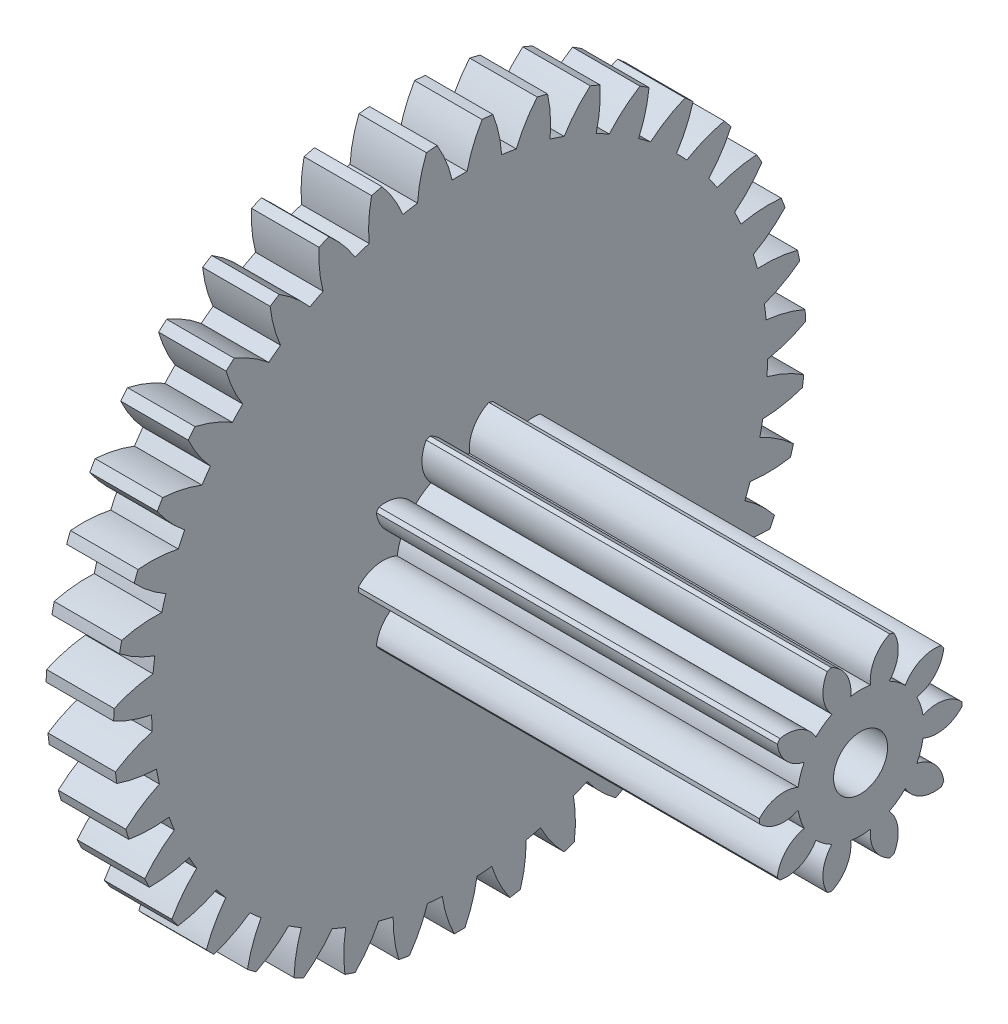
from build123d import *

# Parameters (mm, degrees)
ESQUISSE1_W                         = 1
ESQUISSE1_H                         = 5.125
ENL_V_MAT_EXTRU_1_DEPTH             = 2
ENL_V_MAT_EXTRU_2_DEPTH             = 2
ENL_V_MAT_EXTRU_3_DEPTH             = 2
ENL_V_MAT_EXTRU_4_DEPTH             = 2
ENL_V_MAT_EXTRU_5_DEPTH             = 2
ENL_V_MAT_EXTRU_6_DEPTH             = 2
ENL_V_MAT_EXTRU_7_DEPTH             = 2
ENL_V_MAT_EXTRU_8_DEPTH             = 2
ENL_V_MAT_EXTRU_9_DEPTH             = 2
ENL_V_MAT_EXTRU_10_DEPTH            = 2
ENL_V_MAT_EXTRU_11_DEPTH            = 2
ENL_V_MAT_EXTRU_12_DEPTH            = 2
ENL_V_MAT_EXTRU_13_DEPTH            = 2
ENL_V_MAT_EXTRU_14_DEPTH            = 2
ENL_V_MAT_EXTRU_15_DEPTH            = 2
ENL_V_MAT_EXTRU_16_DEPTH            = 2
ENL_V_MAT_EXTRU_17_DEPTH            = 2
ENL_V_MAT_EXTRU_18_DEPTH            = 2
ENL_V_MAT_EXTRU_19_DEPTH            = 2
ENL_V_MAT_EXTRU_20_DEPTH            = 2
ENL_V_MAT_EXTRU_21_DEPTH            = 2
ENL_V_MAT_EXTRU_22_DEPTH            = 2
ENL_V_MAT_EXTRU_23_DEPTH            = 2
ENL_V_MAT_EXTRU_24_DEPTH            = 2
ENL_V_MAT_EXTRU_25_DEPTH            = 2
ENL_V_MAT_EXTRU_26_DEPTH            = 2
ENL_V_MAT_EXTRU_27_DEPTH            = 2
ENL_V_MAT_EXTRU_28_DEPTH            = 2
ENL_V_MAT_EXTRU_29_DEPTH            = 2
ENL_V_MAT_EXTRU_30_DEPTH            = 2
ENL_V_MAT_EXTRU_31_DEPTH            = 2
ENL_V_MAT_EXTRU_32_DEPTH            = 2
ENL_V_MAT_EXTRU_33_DEPTH            = 2
ENL_V_MAT_EXTRU_34_DEPTH            = 2
ENL_V_MAT_EXTRU_35_DEPTH            = 2
ENL_V_MAT_EXTRU_36_DEPTH            = 2
ENL_V_MAT_EXTRU_37_DEPTH            = 2
ENL_V_MAT_EXTRU_38_DEPTH            = 2
ENL_V_MAT_EXTRU_39_DEPTH            = 2
BOSS_EXTRU_1_DEPTH                  = 5.938524524
DIAM_TRE_DU_PER_AGE_0_8_0_8_1_D     = 0.8
DIAM_TRE_DU_PER_AGE_0_8_0_8_1_DEPTH = 6.938524524


with BuildPart() as part:
    # Esquisse1 → Révolution1 (revolve)
    with BuildSketch(Plane(origin=(0, 0, 0), x_dir=(-1, 0, 0), z_dir=(0, 0, -1))):
        with Locations((-0.5, 2.5625)):
            Rectangle(ESQUISSE1_W, ESQUISSE1_H)
    revolve(axis=Axis((1, 0, 0), (-1, 0, 0)))

    # Esquisse2 → Enlèv. mat.-Extru.1 (cut, through all)
    with BuildSketch(Plane.ZY):
        with BuildLine():
            ThreePointArc((-0.491599352, 5.101367961), (-0.822107814, 5.058632596), (-1.149140058, 4.994507196))
            ThreePointArc((-1.149140058, 4.994507196), (-0.974871828, 4.75090918), (-0.839964848, 4.483496549))
            ThreePointArc((-0.839964848, 4.483496549), (-0.731716058, 4.502429773), (-0.623042589, 4.518749847))
            ThreePointArc((-0.623042589, 4.518749847), (-0.579759423, 4.815121196), (-0.491599352, 5.101367961))
        make_face()
    extrude(amount=-ENL_V_MAT_EXTRU_1_DEPTH, mode=Mode.SUBTRACT)

    # Esquisse3 → Enlèv. mat.-Extru.2 (cut, through all)
    with BuildSketch(Plane.ZY):
        with BuildLine():
            ThreePointArc((0.3330837, 5.114164668), (0, 5.125), (-0.3330837, 5.114164668))
            ThreePointArc((-0.3330837, 5.114164668), (-0.200148067, 4.845766593), (-0.1098841, 4.560176283))
            ThreePointArc((-0.1098841, 4.560176283), (0, 4.5615), (0.1098841, 4.560176283))
            ThreePointArc((0.1098841, 4.560176283), (0.200148067, 4.845766593), (0.3330837, 5.114164668))
        make_face()
    extrude(amount=-ENL_V_MAT_EXTRU_2_DEPTH, mode=Mode.SUBTRACT)

    # Esquisse4 → Enlèv. mat.-Extru.3 (cut, through all)
    with BuildSketch(Plane.ZY):
        with BuildLine():
            ThreePointArc((1.149140058, 4.994507196), (0.822107814, 5.058632596), (0.491599352, 5.101367961))
            ThreePointArc((0.491599352, 5.101367961), (0.579759423, 4.815121196), (0.623042589, 4.518749847))
            ThreePointArc((0.623042589, 4.518749847), (0.731716058, 4.502429773), (0.839964848, 4.483496549))
            ThreePointArc((0.839964848, 4.483496549), (0.974871828, 4.75090918), (1.149140058, 4.994507196))
        make_face()
    extrude(amount=-ENL_V_MAT_EXTRU_3_DEPTH, mode=Mode.SUBTRACT)

    # Esquisse5 → Enlèv. mat.-Extru.4 (cut, through all)
    with BuildSketch(Plane.ZY):
        with BuildLine():
            ThreePointArc((1.935434293, 4.745494611), (1.622923468, 4.861249265), (1.303550238, 4.956448504))
            ThreePointArc((1.303550238, 4.956448504), (1.34465145, 4.65976669), (1.339832802, 4.360290164))
            ThreePointArc((1.339832802, 4.360290164), (1.444481054, 4.32674898), (1.548290948, 4.290696609))
            ThreePointArc((1.548290948, 4.290696609), (1.724346921, 4.533005716), (1.935434293, 4.745494611))
        make_face()
    extrude(amount=-ENL_V_MAT_EXTRU_4_DEPTH, mode=Mode.SUBTRACT)

    # Esquisse6 → Enlèv. mat.-Extru.5 (cut, through all)
    with BuildSketch(Plane.ZY):
        with BuildLine():
            ThreePointArc((2.671601796, 4.373576208), (2.381706257, 4.537962131), (2.081739858, 4.683159635))
            ThreePointArc((2.081739858, 4.683159635), (2.07471771, 4.383726673), (2.021922049, 4.088901256))
            ThreePointArc((2.021922049, 4.088901256), (2.119834749, 4.039007661), (2.216517126, 3.986769881))
            ThreePointArc((2.216517126, 3.986769881), (2.429162334, 4.197699784), (2.671601796, 4.373576208))
        make_face()
    extrude(amount=-ENL_V_MAT_EXTRU_5_DEPTH, mode=Mode.SUBTRACT)

    # Esquisse7 → Enlèv. mat.-Extru.6 (cut, through all)
    with BuildSketch(Plane.ZY):
        with BuildLine():
            ThreePointArc((3.338576216, 3.888384478), (3.078804104, 4.097144162), (2.806013509, 4.28857939))
            ThreePointArc((2.806013509, 4.28857939), (2.751049871, 3.994150439), (2.651644577, 3.711611952))
            ThreePointArc((2.651644577, 3.711611952), (2.740285838, 3.646658165), (2.827336674, 3.579587907))
            ThreePointArc((2.827336674, 3.579587907), (3.071063719, 3.753675633), (3.338576216, 3.888384478))
        make_face()
    extrude(amount=-ENL_V_MAT_EXTRU_6_DEPTH, mode=Mode.SUBTRACT)

    # Esquisse8 → Enlèv. mat.-Extru.7 (cut, through all)
    with BuildSketch(Plane.ZY):
        with BuildLine():
            ThreePointArc((3.919083265, 3.302485634), (3.696162543, 3.550212312), (3.457612884, 3.782927193))
            ThreePointArc((3.457612884, 3.782927193), (3.356131286, 3.501127806), (3.212690904, 3.23819385))
            ThreePointArc((3.212690904, 3.23819385), (3.289764964, 3.159862139), (3.364929688, 3.079696486))
            ThreePointArc((3.364929688, 3.079696486), (3.633426167, 3.212433254), (3.919083265, 3.302485634))
        make_face()
    extrude(amount=-ENL_V_MAT_EXTRU_7_DEPTH, mode=Mode.SUBTRACT)

    # Esquisse9 → Enlèv. mat.-Extru.8 (cut, through all)
    with BuildSketch(Plane.ZY):
        with BuildLine():
            ThreePointArc((4.398088117, 2.631054146), (4.217792313, 2.911331827), (4.019661902, 3.179299168))
            ThreePointArc((4.019661902, 3.179299168), (3.874290663, 2.917427803), (3.690530223, 2.680908227))
            ThreePointArc((3.690530223, 2.680908227), (3.754040904, 2.591227342), (3.81537279, 2.500042544))
            ThreePointArc((3.81537279, 2.500042544), (4.101684785, 2.587990542), (4.398088117, 2.631054146))
        make_face()
    extrude(amount=-ENL_V_MAT_EXTRU_8_DEPTH, mode=Mode.SUBTRACT)

    # Esquisse10 → Enlèv. mat.-Extru.9 (cut, through all)
    with BuildSketch(Plane.ZY):
        with BuildLine():
            ThreePointArc((4.763184796, 1.891479738), (4.630183477, 2.197049377), (4.477603787, 2.493328964))
            ThreePointArc((4.477603787, 2.493328964), (4.292107947, 2.258167951), (4.072786749, 2.054188489))
            ThreePointArc((4.072786749, 2.054188489), (4.121089157, 1.955481119), (4.166999741, 1.855638814))
            ThreePointArc((4.166999741, 1.855638814), (4.463711922, 1.896520234), (4.763184796, 1.891479738))
        make_face()
    extrude(amount=-ENL_V_MAT_EXTRU_9_DEPTH, mode=Mode.SUBTRACT)

    # Esquisse11 → Enlèv. mat.-Extru.10 (cut, through all)
    with BuildSketch(Plane.ZY):
        with BuildLine():
            ThreePointArc((5.004917491, 1.102916998), (4.922655322, 1.425864503), (4.819578087, 1.74278285))
            ThreePointArc((4.819578087, 1.74278285), (4.59876189, 1.540422736), (4.349560237, 1.374266349))
            ThreePointArc((4.349560237, 1.374266349), (4.381403366, 1.269088962), (4.410703588, 1.163175012))
            ThreePointArc((4.410703588, 1.163175012), (4.710131265, 1.155931048), (5.004917491, 1.102916998))
        make_face()
    extrude(amount=-ENL_V_MAT_EXTRU_10_DEPTH, mode=Mode.SUBTRACT)

    # Esquisse12 → Enlèv. mat.-Extru.11 (cut, through all)
    with BuildSketch(Plane.ZY):
        with BuildLine():
            ThreePointArc((5.117025453, 0.285789287), (5.08763298, 0.617750486), (5.036727846, 0.947099576))
            ThreePointArc((5.036727846, 0.947099576), (4.786310315, 0.782781381), (4.513682399, 0.658751432))
            ThreePointArc((4.513682399, 0.658751432), (4.528241529, 0.549828067), (4.540172528, 0.440585589))
            ThreePointArc((4.540172528, 0.440585589), (4.834560682, 0.385403856), (5.117025453, 0.285789287))
        make_face()
    extrude(amount=-ENL_V_MAT_EXTRU_11_DEPTH, mode=Mode.SUBTRACT)

    # Esquisse13 → Enlèv. mat.-Extru.12 (cut, through all)
    with BuildSketch(Plane.ZY):
        with BuildLine():
            ThreePointArc((5.096605143, -0.538740217), (5.120843616, -0.206362943), (5.123428999, 0.12688692))
            ThreePointArc((5.123428999, 0.12688692), (4.849895818, 0.0048664), (4.560902559, -0.073824801))
            ThreePointArc((4.560902559, -0.073824801), (4.557800615, -0.183673086), (4.552053385, -0.293414769))
            ThreePointArc((4.552053385, -0.293414769), (4.833777517, -0.395105094), (5.096605143, -0.538740217))
        make_face()
    extrude(amount=-ENL_V_MAT_EXTRU_12_DEPTH, mode=Mode.SUBTRACT)

    # Esquisse14 → Enlèv. mat.-Extru.13 (cut, through all)
    with BuildSketch(Plane.ZY):
        with BuildLine():
            ThreePointArc((4.944185436, -1.349316631), (5.021427092, -1.025131681), (5.077436033, -0.69661204))
            ThreePointArc((5.077436033, -0.69661204), (4.787871566, -0.773174619), (4.489997737, -0.804489011))
            ThreePointArc((4.489997737, -0.804489011), (4.469315059, -0.912417202), (4.446038451, -1.019815839))
            ThreePointArc((4.446038451, -1.019815839), (4.707802054, -1.16538103), (4.944185436, -1.349316631))
        make_face()
    extrude(amount=-ENL_V_MAT_EXTRU_13_DEPTH, mode=Mode.SUBTRACT)

    # Esquisse15 → Enlèv. mat.-Extru.14 (cut, through all)
    with BuildSketch(Plane.ZY):
        with BuildLine():
            ThreePointArc((4.663713924, -2.124946454), (4.791958244, -1.817350046), (4.89994014, -1.502069115))
            ThreePointArc((4.89994014, -1.502069115), (4.601843956, -1.531190821), (4.302804333, -1.514317378))
            ThreePointArc((4.302804333, -1.514317378), (4.265076591, -1.617530192), (4.224873456, -1.719804214))
            ThreePointArc((4.224873456, -1.719804214), (4.45989699, -1.905474209), (4.663713924, -2.124946454))
        make_face()
    extrude(amount=-ENL_V_MAT_EXTRU_14_DEPTH, mode=Mode.SUBTRACT)

    # Esquisse16 → Enlèv. mat.-Extru.15 (cut, through all)
    with BuildSketch(Plane.ZY):
        with BuildLine():
            ThreePointArc((4.262454672, -2.845541279), (4.438380194, -2.5625), (4.595538371, -2.268623388))
            ThreePointArc((4.595538371, -2.268623388), (4.296631004, -2.249549986), (4.004170557, -2.18492572))
            ThreePointArc((4.004170557, -2.18492572), (3.950374879, -2.28075), (3.894286457, -2.375250564))
            ThreePointArc((3.894286457, -2.375250564), (4.096482937, -2.596216607), (4.262454672, -2.845541279))
        make_face()
    extrude(amount=-ENL_V_MAT_EXTRU_15_DEPTH, mode=Mode.SUBTRACT)

    # Esquisse17 → Enlèv. mat.-Extru.16 (cut, through all)
    with BuildSketch(Plane.ZY):
        with BuildLine():
            ThreePointArc((3.750800082, -3.492438081), (3.969850429, -3.24128255), (4.172114573, -2.976421508))
            ThreePointArc((4.172114573, -2.976421508), (3.880137567, -2.909646987), (3.601830867, -2.798945633))
            ThreePointArc((3.601830867, -2.798945633), (3.533360533, -2.884899581), (3.462839485, -2.969179171))
            ThreePointArc((3.462839485, -2.969179171), (3.626972127, -3.219718359), (3.750800082, -3.492438081))
        make_face()
    extrude(amount=-ENL_V_MAT_EXTRU_16_DEPTH, mode=Mode.SUBTRACT)

    # Esquisse18 → Enlèv. mat.-Extru.17 (cut, through all)
    with BuildSketch(Plane.ZY):
        with BuildLine():
            ThreePointArc((3.14200174, -4.04888257), (3.398503623, -3.836117584), (3.640635198, -3.607131873))
            ThreePointArc((3.640635198, -3.607131873), (3.363150604, -3.49438566), (3.106205649, -3.340474325))
            ThreePointArc((3.106205649, -3.340474325), (3.024834006, -3.414331778), (2.941706789, -3.486207598))
            ThreePointArc((2.941706789, -3.486207598), (3.063524645, -3.759831097), (3.14200174, -4.04888257))
        make_face()
    extrude(amount=-ENL_V_MAT_EXTRU_17_DEPTH, mode=Mode.SUBTRACT)

    # Esquisse19 → Enlèv. mat.-Extru.18 (cut, through all)
    with BuildSketch(Plane.ZY):
        with BuildLine():
            ThreePointArc((2.451827203, -4.500463128), (2.739137359, -4.331599188), (3.014865285, -4.144419418))
            ThreePointArc((3.014865285, -4.144419418), (2.759059808, -3.988621579), (2.530131336, -3.795486487))
            ThreePointArc((2.530131336, -3.795486487), (2.437965866, -3.855334575), (2.344385433, -3.912945079))
            ThreePointArc((2.344385433, -3.912945079), (2.420733483, -4.202566184), (2.451827203, -4.500463128))
        make_face()
    extrude(amount=-ENL_V_MAT_EXTRU_18_DEPTH, mode=Mode.SUBTRACT)

    # Esquisse20 → Enlèv. mat.-Extru.19 (cut, through all)
    with BuildSketch(Plane.ZY):
        with BuildLine():
            ThreePointArc((1.69815163, -4.835484054), (2.008828876, -4.714894649), (2.311011944, -4.574368677))
            ThreePointArc((2.311011944, -4.574368677), (2.083510811, -4.379554295), (1.888527951, -4.152197542))
            ThreePointArc((1.888527951, -4.152197542), (1.787955691, -4.196486232), (1.686345725, -4.238339338))
            ThreePointArc((1.686345725, -4.238339338), (1.715246596, -4.536457014), (1.69815163, -4.835484054))
        make_face()
    extrude(amount=-ENL_V_MAT_EXTRU_19_DEPTH, mode=Mode.SUBTRACT)

    # Esquisse21 → Enlèv. mat.-Extru.20 (cut, through all)
    with BuildSketch(Plane.ZY):
        with BuildLine():
            ThreePointArc((0.900494822, -5.045268484), (1.226492779, -4.976076814), (1.547304608, -4.88584419))
            ThreePointArc((1.547304608, -4.88584419), (1.35399998, -4.657058855), (1.198012684, -4.401368862))
            ThreePointArc((1.198012684, -4.401368862), (1.091638403, -4.4289511), (0.984630549, -4.453962835))
            ThreePointArc((0.984630549, -4.453962835), (0.965335723, -4.75285599), (0.900494822, -5.045268484))
        make_face()
    extrude(amount=-ENL_V_MAT_EXTRU_20_DEPTH, mode=Mode.SUBTRACT)

    # Esquisse22 → Enlèv. mat.-Extru.21 (cut, through all)
    with BuildSketch(Plane.ZY):
        with BuildLine():
            ThreePointArc((0.079515671, -5.12438311), (0.412391165, -5.108381204), (0.743522895, -5.070778905))
            ThreePointArc((0.743522895, -5.070778905), (0.589421259, -4.813948037), (0.476469518, -4.53654704))
            ThreePointArc((0.476469518, -4.53654704), (0.367048253, -4.546708461), (0.257413959, -4.554231033))
            ThreePointArc((0.257413959, -4.554231033), (0.190423162, -4.846158493), (0.079515671, -5.12438311))
        make_face()
    extrude(amount=-ENL_V_MAT_EXTRU_21_DEPTH, mode=Mode.SUBTRACT)

    # Esquisse23 → Enlèv. mat.-Extru.22 (cut, through all)
    with BuildSketch(Plane.ZY):
        with BuildLine():
            ThreePointArc((-0.743522895, -5.070778905), (-0.412391165, -5.108381204), (-0.079515671, -5.12438311))
            ThreePointArc((-0.079515671, -5.12438311), (-0.190423162, -4.846158493), (-0.257413959, -4.554231033))
            ThreePointArc((-0.257413959, -4.554231033), (-0.367048253, -4.546708461), (-0.476469518, -4.53654704))
            ThreePointArc((-0.476469518, -4.53654704), (-0.589421259, -4.813948037), (-0.743522895, -5.070778905))
        make_face()
    extrude(amount=-ENL_V_MAT_EXTRU_22_DEPTH, mode=Mode.SUBTRACT)

    # Esquisse24 → Enlèv. mat.-Extru.23 (cut, through all)
    with BuildSketch(Plane.ZY):
        with BuildLine():
            ThreePointArc((-1.547304608, -4.88584419), (-1.226492779, -4.976076814), (-0.900494822, -5.045268484))
            ThreePointArc((-0.900494822, -5.045268484), (-0.965335723, -4.75285599), (-0.984630549, -4.453962835))
            ThreePointArc((-0.984630549, -4.453962835), (-1.091638403, -4.4289511), (-1.198012684, -4.401368862))
            ThreePointArc((-1.198012684, -4.401368862), (-1.35399998, -4.657058855), (-1.547304608, -4.88584419))
        make_face()
    extrude(amount=-ENL_V_MAT_EXTRU_23_DEPTH, mode=Mode.SUBTRACT)

    # Esquisse25 → Enlèv. mat.-Extru.24 (cut, through all)
    with BuildSketch(Plane.ZY):
        with BuildLine():
            ThreePointArc((-2.311011944, -4.574368677), (-2.008828876, -4.714894649), (-1.69815163, -4.835484054))
            ThreePointArc((-1.69815163, -4.835484054), (-1.715246596, -4.536457014), (-1.686345725, -4.238339338))
            ThreePointArc((-1.686345725, -4.238339338), (-1.787955691, -4.196486232), (-1.888527951, -4.152197542))
            ThreePointArc((-1.888527951, -4.152197542), (-2.083510811, -4.379554295), (-2.311011944, -4.574368677))
        make_face()
    extrude(amount=-ENL_V_MAT_EXTRU_24_DEPTH, mode=Mode.SUBTRACT)

    # Esquisse26 → Enlèv. mat.-Extru.25 (cut, through all)
    with BuildSketch(Plane.ZY):
        with BuildLine():
            ThreePointArc((-3.014865285, -4.144419418), (-2.739137359, -4.331599188), (-2.451827203, -4.500463128))
            ThreePointArc((-2.451827203, -4.500463128), (-2.420733483, -4.202566184), (-2.344385433, -3.912945079))
            ThreePointArc((-2.344385433, -3.912945079), (-2.437965866, -3.855334575), (-2.530131336, -3.795486487))
            ThreePointArc((-2.530131336, -3.795486487), (-2.759059808, -3.988621579), (-3.014865285, -4.144419418))
        make_face()
    extrude(amount=-ENL_V_MAT_EXTRU_25_DEPTH, mode=Mode.SUBTRACT)

    # Esquisse27 → Enlèv. mat.-Extru.26 (cut, through all)
    with BuildSketch(Plane.ZY):
        with BuildLine():
            ThreePointArc((-3.640635198, -3.607131873), (-3.398503623, -3.836117584), (-3.14200174, -4.04888257))
            ThreePointArc((-3.14200174, -4.04888257), (-3.063524645, -3.759831097), (-2.941706789, -3.486207598))
            ThreePointArc((-2.941706789, -3.486207598), (-3.024834006, -3.414331778), (-3.106205649, -3.340474325))
            ThreePointArc((-3.106205649, -3.340474325), (-3.363150604, -3.49438566), (-3.640635198, -3.607131873))
        make_face()
    extrude(amount=-ENL_V_MAT_EXTRU_26_DEPTH, mode=Mode.SUBTRACT)

    # Esquisse28 → Enlèv. mat.-Extru.27 (cut, through all)
    with BuildSketch(Plane.ZY):
        with BuildLine():
            ThreePointArc((-4.172114573, -2.976421508), (-3.969850429, -3.24128255), (-3.750800082, -3.492438081))
            ThreePointArc((-3.750800082, -3.492438081), (-3.626972127, -3.219718359), (-3.462839485, -2.969179171))
            ThreePointArc((-3.462839485, -2.969179171), (-3.533360533, -2.884899581), (-3.601830867, -2.798945633))
            ThreePointArc((-3.601830867, -2.798945633), (-3.880137567, -2.909646987), (-4.172114573, -2.976421508))
        make_face()
    extrude(amount=-ENL_V_MAT_EXTRU_27_DEPTH, mode=Mode.SUBTRACT)

    # Esquisse29 → Enlèv. mat.-Extru.28 (cut, through all)
    with BuildSketch(Plane.ZY):
        with BuildLine():
            ThreePointArc((-4.595538371, -2.268623388), (-4.438380194, -2.5625), (-4.262454672, -2.845541279))
            ThreePointArc((-4.262454672, -2.845541279), (-4.096482937, -2.596216607), (-3.894286457, -2.375250564))
            ThreePointArc((-3.894286457, -2.375250564), (-3.950374879, -2.28075), (-4.004170557, -2.18492572))
            ThreePointArc((-4.004170557, -2.18492572), (-4.296631004, -2.249549986), (-4.595538371, -2.268623388))
        make_face()
    extrude(amount=-ENL_V_MAT_EXTRU_28_DEPTH, mode=Mode.SUBTRACT)

    # Esquisse30 → Enlèv. mat.-Extru.29 (cut, through all)
    with BuildSketch(Plane.ZY):
        with BuildLine():
            ThreePointArc((-4.89994014, -1.502069115), (-4.791958244, -1.817350046), (-4.663713924, -2.124946454))
            ThreePointArc((-4.663713924, -2.124946454), (-4.45989699, -1.905474209), (-4.224873456, -1.719804214))
            ThreePointArc((-4.224873456, -1.719804214), (-4.265076591, -1.617530192), (-4.302804333, -1.514317378))
            ThreePointArc((-4.302804333, -1.514317378), (-4.601843956, -1.531190821), (-4.89994014, -1.502069115))
        make_face()
    extrude(amount=-ENL_V_MAT_EXTRU_29_DEPTH, mode=Mode.SUBTRACT)

    # Esquisse31 → Enlèv. mat.-Extru.30 (cut, through all)
    with BuildSketch(Plane.ZY):
        with BuildLine():
            ThreePointArc((-5.077436033, -0.69661204), (-5.021427092, -1.025131681), (-4.944185436, -1.349316631))
            ThreePointArc((-4.944185436, -1.349316631), (-4.707802054, -1.16538103), (-4.446038451, -1.019815839))
            ThreePointArc((-4.446038451, -1.019815839), (-4.469315059, -0.912417202), (-4.489997737, -0.804489011))
            ThreePointArc((-4.489997737, -0.804489011), (-4.787871566, -0.773174619), (-5.077436033, -0.69661204))
        make_face()
    extrude(amount=-ENL_V_MAT_EXTRU_30_DEPTH, mode=Mode.SUBTRACT)

    # Esquisse32 → Enlèv. mat.-Extru.31 (cut, through all)
    with BuildSketch(Plane.ZY):
        with BuildLine():
            ThreePointArc((-5.123428999, 0.12688692), (-5.120843616, -0.206362943), (-5.096605143, -0.538740217))
            ThreePointArc((-5.096605143, -0.538740217), (-4.833777517, -0.395105094), (-4.552053385, -0.293414769))
            ThreePointArc((-4.552053385, -0.293414769), (-4.557800615, -0.183673086), (-4.560902559, -0.073824801))
            ThreePointArc((-4.560902559, -0.073824801), (-4.849895818, 0.0048664), (-5.123428999, 0.12688692))
        make_face()
    extrude(amount=-ENL_V_MAT_EXTRU_31_DEPTH, mode=Mode.SUBTRACT)

    # Esquisse33 → Enlèv. mat.-Extru.32 (cut, through all)
    with BuildSketch(Plane.ZY):
        with BuildLine():
            ThreePointArc((-5.036727846, 0.947099576), (-5.08763298, 0.617750486), (-5.117025453, 0.285789287))
            ThreePointArc((-5.117025453, 0.285789287), (-4.834560682, 0.385403856), (-4.540172528, 0.440585589))
            ThreePointArc((-4.540172528, 0.440585589), (-4.528241529, 0.549828067), (-4.513682399, 0.658751432))
            ThreePointArc((-4.513682399, 0.658751432), (-4.786310315, 0.782781381), (-5.036727846, 0.947099576))
        make_face()
    extrude(amount=-ENL_V_MAT_EXTRU_32_DEPTH, mode=Mode.SUBTRACT)

    # Esquisse34 → Enlèv. mat.-Extru.33 (cut, through all)
    with BuildSketch(Plane.ZY):
        with BuildLine():
            ThreePointArc((-4.819578087, 1.74278285), (-4.922655322, 1.425864503), (-5.004917491, 1.102916998))
            ThreePointArc((-5.004917491, 1.102916998), (-4.710131265, 1.155931048), (-4.410703588, 1.163175012))
            ThreePointArc((-4.410703588, 1.163175012), (-4.381403366, 1.269088962), (-4.349560237, 1.374266349))
            ThreePointArc((-4.349560237, 1.374266349), (-4.59876189, 1.540422736), (-4.819578087, 1.74278285))
        make_face()
    extrude(amount=-ENL_V_MAT_EXTRU_33_DEPTH, mode=Mode.SUBTRACT)

    # Esquisse35 → Enlèv. mat.-Extru.34 (cut, through all)
    with BuildSketch(Plane.ZY):
        with BuildLine():
            ThreePointArc((-4.477603787, 2.493328964), (-4.630183477, 2.197049377), (-4.763184796, 1.891479738))
            ThreePointArc((-4.763184796, 1.891479738), (-4.463711922, 1.896520234), (-4.166999741, 1.855638814))
            ThreePointArc((-4.166999741, 1.855638814), (-4.121089157, 1.955481119), (-4.072786749, 2.054188489))
            ThreePointArc((-4.072786749, 2.054188489), (-4.292107947, 2.258167951), (-4.477603787, 2.493328964))
        make_face()
    extrude(amount=-ENL_V_MAT_EXTRU_34_DEPTH, mode=Mode.SUBTRACT)

    # Esquisse36 → Enlèv. mat.-Extru.35 (cut, through all)
    with BuildSketch(Plane.ZY):
        with BuildLine():
            ThreePointArc((-4.019661902, 3.179299168), (-4.217792313, 2.911331827), (-4.398088117, 2.631054146))
            ThreePointArc((-4.398088117, 2.631054146), (-4.101684785, 2.587990542), (-3.81537279, 2.500042544))
            ThreePointArc((-3.81537279, 2.500042544), (-3.754040904, 2.591227342), (-3.690530223, 2.680908227))
            ThreePointArc((-3.690530223, 2.680908227), (-3.874290663, 2.917427803), (-4.019661902, 3.179299168))
        make_face()
    extrude(amount=-ENL_V_MAT_EXTRU_35_DEPTH, mode=Mode.SUBTRACT)

    # Esquisse37 → Enlèv. mat.-Extru.36 (cut, through all)
    with BuildSketch(Plane.ZY):
        with BuildLine():
            ThreePointArc((-3.457612884, 3.782927193), (-3.696162543, 3.550212312), (-3.919083265, 3.302485634))
            ThreePointArc((-3.919083265, 3.302485634), (-3.633426167, 3.212433254), (-3.364929688, 3.079696486))
            ThreePointArc((-3.364929688, 3.079696486), (-3.289764964, 3.159862139), (-3.212690904, 3.23819385))
            ThreePointArc((-3.212690904, 3.23819385), (-3.356131286, 3.501127806), (-3.457612884, 3.782927193))
        make_face()
    extrude(amount=-ENL_V_MAT_EXTRU_36_DEPTH, mode=Mode.SUBTRACT)

    # Esquisse38 → Enlèv. mat.-Extru.37 (cut, through all)
    with BuildSketch(Plane.ZY):
        with BuildLine():
            ThreePointArc((-2.806013509, 4.28857939), (-3.078804104, 4.097144162), (-3.338576216, 3.888384478))
            ThreePointArc((-3.338576216, 3.888384478), (-3.071063719, 3.753675633), (-2.827336674, 3.579587907))
            ThreePointArc((-2.827336674, 3.579587907), (-2.740285838, 3.646658165), (-2.651644577, 3.711611952))
            ThreePointArc((-2.651644577, 3.711611952), (-2.751049871, 3.994150439), (-2.806013509, 4.28857939))
        make_face()
    extrude(amount=-ENL_V_MAT_EXTRU_37_DEPTH, mode=Mode.SUBTRACT)

    # Esquisse39 → Enlèv. mat.-Extru.38 (cut, through all)
    with BuildSketch(Plane.ZY):
        with BuildLine():
            ThreePointArc((-2.081739858, 4.683159635), (-2.381706257, 4.537962131), (-2.671601796, 4.373576208))
            ThreePointArc((-2.671601796, 4.373576208), (-2.429162334, 4.197699784), (-2.216517126, 3.986769881))
            ThreePointArc((-2.216517126, 3.986769881), (-2.119834749, 4.039007661), (-2.021922049, 4.088901256))
            ThreePointArc((-2.021922049, 4.088901256), (-2.07471771, 4.383726673), (-2.081739858, 4.683159635))
        make_face()
    extrude(amount=-ENL_V_MAT_EXTRU_38_DEPTH, mode=Mode.SUBTRACT)

    # Esquisse40 → Enlèv. mat.-Extru.39 (cut, through all)
    with BuildSketch(Plane.ZY):
        with BuildLine():
            ThreePointArc((-1.303550238, 4.956448504), (-1.622923468, 4.861249265), (-1.935434293, 4.745494611))
            ThreePointArc((-1.935434293, 4.745494611), (-1.724346921, 4.533005716), (-1.548290948, 4.290696609))
            ThreePointArc((-1.548290948, 4.290696609), (-1.444481054, 4.32674898), (-1.339832802, 4.360290164))
            ThreePointArc((-1.339832802, 4.360290164), (-1.34465145, 4.65976669), (-1.303550238, 4.956448504))
        make_face()
    extrude(amount=-ENL_V_MAT_EXTRU_39_DEPTH, mode=Mode.SUBTRACT)

    # Esquisse41 → Boss.-Extru.1 (add)
    with BuildSketch(Plane(origin=(1, 0, 0), x_dir=(0, 0, -1), z_dir=(1, 0, 0))):
        with BuildLine():
            ThreePointArc((0.662076845, 0.662334131), (0.888221597, 0.871258232), (1.193891961, 0.908086992))
            ThreePointArc((1.193891961, 0.908086992), (1.213525492, 0.881677878), (1.232574957, 0.854844416))
            ThreePointArc((1.232574957, 0.854844416), (1.103091387, 0.575515338), (0.834510188, 0.424999995))
            ThreePointArc((0.834510188, 0.424999995), (0.890664428, 0.289394415), (0.924941654, 0.146680563))
            ThreePointArc((0.924941654, 0.146680563), (1.230699107, 0.18277916), (1.499639028, 0.032905721))
            ThreePointArc((1.499639028, 0.032905721), (1.5, 0), (1.499639028, -0.032905721))
            ThreePointArc((1.499639028, -0.032905721), (1.230699107, -0.18277916), (0.924941654, -0.146680563))
            ThreePointArc((0.924941654, -0.146680563), (0.890664428, -0.289394415), (0.834510188, -0.424999995))
            ThreePointArc((0.834510188, -0.424999995), (1.103091387, -0.575515338), (1.232574957, -0.854844416))
            ThreePointArc((1.232574957, -0.854844416), (1.213525492, -0.881677878), (1.193891961, -0.908086992))
            ThreePointArc((1.193891961, -0.908086992), (0.888221597, -0.871258232), (0.662076845, -0.662334131))
            ThreePointArc((0.662076845, -0.662334131), (0.550460889, -0.757644415), (0.425324195, -0.834345))
            ThreePointArc((0.425324195, -0.834345), (0.55414025, -1.113982538), (0.494709146, -1.416073042))
            ThreePointArc((0.494709146, -1.416073042), (0.463525492, -1.426584774), (0.432118744, -1.436409897))
            ThreePointArc((0.432118744, -1.436409897), (0.206473627, -1.226946272), (0.146321185, -0.924998573))
            ThreePointArc((0.146321185, -0.924998573), (0, -0.9365), (-0.146321185, -0.924998573))
            ThreePointArc((-0.146321185, -0.924998573), (-0.206473627, -1.226946272), (-0.432118744, -1.436409897))
            ThreePointArc((-0.432118744, -1.436409897), (-0.463525492, -1.426584774), (-0.494709146, -1.416073042))
            ThreePointArc((-0.494709146, -1.416073042), (-0.55414025, -1.113982538), (-0.425324195, -0.834345))
            ThreePointArc((-0.425324195, -0.834345), (-0.550460889, -0.757644415), (-0.662076845, -0.662334131))
            ThreePointArc((-0.662076845, -0.662334131), (-0.888221597, -0.871258232), (-1.193891961, -0.908086992))
            ThreePointArc((-1.193891961, -0.908086992), (-1.213525492, -0.881677878), (-1.232574957, -0.854844416))
            ThreePointArc((-1.232574957, -0.854844416), (-1.103091387, -0.575515338), (-0.834510188, -0.424999995))
            ThreePointArc((-0.834510188, -0.424999995), (-0.890664428, -0.289394415), (-0.924941654, -0.146680563))
            ThreePointArc((-0.924941654, -0.146680563), (-1.230699107, -0.18277916), (-1.499639028, -0.032905721))
            ThreePointArc((-1.499639028, -0.032905721), (-1.5, 0), (-1.499639028, 0.032905721))
            ThreePointArc((-1.499639028, 0.032905721), (-1.230699107, 0.18277916), (-0.924941654, 0.146680563))
            ThreePointArc((-0.924941654, 0.146680563), (-0.890664428, 0.289394415), (-0.834510188, 0.424999995))
            ThreePointArc((-0.834510188, 0.424999995), (-1.103091387, 0.575515338), (-1.232574957, 0.854844416))
            ThreePointArc((-1.232574957, 0.854844416), (-1.213525492, 0.881677878), (-1.193891961, 0.908086992))
            ThreePointArc((-1.193891961, 0.908086992), (-0.888221597, 0.871258232), (-0.662076845, 0.662334131))
            ThreePointArc((-0.662076845, 0.662334131), (-0.550460889, 0.757644415), (-0.425324195, 0.834345))
            ThreePointArc((-0.425324195, 0.834345), (-0.55414025, 1.113982538), (-0.494709146, 1.416073042))
            ThreePointArc((-0.494709146, 1.416073042), (-0.463525492, 1.426584774), (-0.432118744, 1.436409897))
            ThreePointArc((-0.432118744, 1.436409897), (-0.206473627, 1.226946272), (-0.146321185, 0.924998573))
            ThreePointArc((-0.146321185, 0.924998573), (0, 0.9365), (0.146321185, 0.924998573))
            ThreePointArc((0.146321185, 0.924998573), (0.206473627, 1.226946272), (0.432118744, 1.436409897))
            ThreePointArc((0.432118744, 1.436409897), (0.463525492, 1.426584774), (0.494709146, 1.416073042))
            ThreePointArc((0.494709146, 1.416073042), (0.55414025, 1.113982538), (0.425324195, 0.834345))
            ThreePointArc((0.425324195, 0.834345), (0.550460889, 0.757644415), (0.662076845, 0.662334131))
        make_face()
    extrude(amount=BOSS_EXTRU_1_DEPTH)

    # Diamètre du perçage Ø0.8 (0.8)1
    with Locations(Plane.ZY):
        with Locations((0, 0)):
            Hole(DIAM_TRE_DU_PER_AGE_0_8_0_8_1_D / 2, depth=DIAM_TRE_DU_PER_AGE_0_8_0_8_1_DEPTH)


solid = part.part
